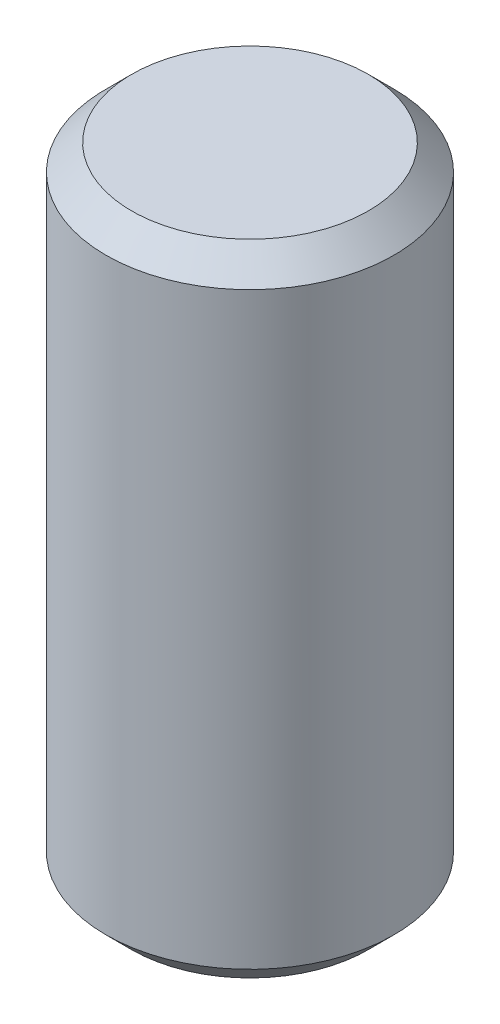
from build123d import *

# Parameters (mm, degrees)
SKETCH1_W     = 2.8575
SKETCH1_H     = 12.7
CHAMFER1_SIZE = 0.508


with BuildPart() as part:
    # Sketch1 → Revolve1 (revolve)
    with BuildSketch(Plane.XY):
        with Locations((1.42875, 0)):
            Rectangle(SKETCH1_W, SKETCH1_H)
    revolve(axis=Axis((0, 6.080207887, 0), (0, -1, 0)))

    # Chamfer1
    chamfer1_edges = [part.edges().sort_by_distance(p)[0] for p in [
        (-2.8575, 6.35, 0),
        (-2.8575, -6.35, 0),
    ]]
    chamfer(chamfer1_edges, length=CHAMFER1_SIZE)


solid = part.part
